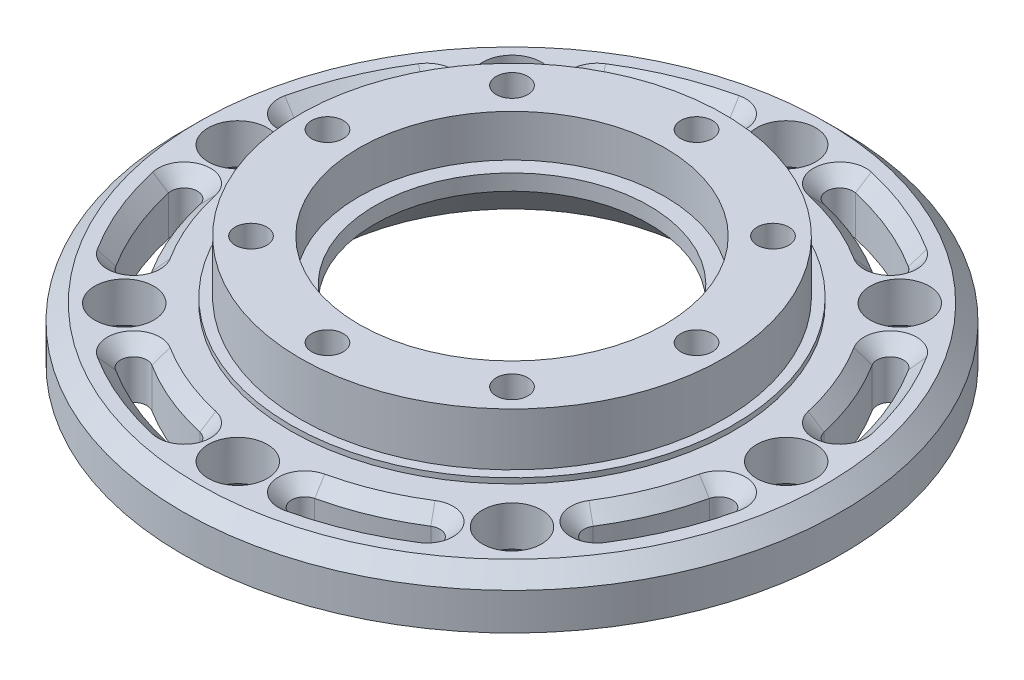
from build123d import *

# Parameters (mm, degrees)
SKETCH1_R            = 62.5
SKETCH1_R_2          = 5.5
SKETCH1_R_3          = 41.5
BOSS_EXTRUDE1_DEPTH  = 10
SKETCH2_R            = 41.5
SKETCH2_R_2          = 3.5
SKETCH2_R_3          = 30
BOSS_EXTRUDE2_DEPTH  = 10
BOSS_EXTRUDE3_START  = -20
SKETCH3_R            = 3.5
BOSS_EXTRUDE3_DEPTH  = 10
SKETCH4_R            = 41.5
SKETCH4_R_2          = 40
CUT_EXTRUDE1_DEPTH   = 10
CHAMFER1_SIZE        = 3
CUT_EXTRUDE4_DEPTH   = 13
BOSS_EXTRUDE4_START  = 1
SKETCH10_R           = 42
SKETCH10_R_2         = 40
BOSS_EXTRUDE4_DEPTH  = 1
BOSS_EXTRUDE9_DEPTH  = 10
CHAMFER7_SIZE        = 2.5
SKETCH18_R           = 3.5
BOSS_EXTRUDE10_DEPTH = 10
SKETCH19_R           = 3
CUT_EXTRUDE7_DEPTH   = 5
CUT_EXTRUDE8_DEPTH   = 15
CHAMFER9_SIZE        = 2.5
SKETCH21_R           = 5.6
CUT_EXTRUDE9_DEPTH   = 15
BOSS_EXTRUDE11_START = -20
SKETCH22_R           = 30
SKETCH22_R_2         = 26
BOSS_EXTRUDE11_DEPTH = 15
SKETCH23_R           = 30
SKETCH23_R_2         = 29
BOSS_EXTRUDE12_DEPTH = 5
CHAMFER10_SIZE       = 10
CUT_EXTRUDE10_START  = -2
SKETCH24_R           = 29
SKETCH24_R_2         = 26
CUT_EXTRUDE10_DEPTH  = 2
BOSS_EXTRUDE13_START = 1
SKETCH25_R           = 40
SKETCH25_R_2         = 29
SKETCH25_R_3         = 3
BOSS_EXTRUDE13_DEPTH = 1
BOSS_EXTRUDE14_START = 10
SKETCH26_R           = 40.15
SKETCH26_R_2         = 40
BOSS_EXTRUDE14_DEPTH = 10


with BuildPart() as part:
    # Sketch1 → Boss-Extrude1 (new body)
    with BuildSketch(Plane(origin=(0, 0, 0), x_dir=(1, 0, 0), z_dir=(0, 1, 0))):
        with Locations(Location((0, 0, 0), (0, 0, 270))):
            Circle(SKETCH1_R)
        with Locations(Location((-52, 0, 0), (0, 0, 270))):
            Circle(SKETCH1_R_2, mode=Mode.SUBTRACT)
        with Locations(Location((-36.769552622, 36.769552622, 0), (0, 0, 270))):
            Circle(SKETCH1_R_2, mode=Mode.SUBTRACT)
        with Locations(Location((0, 52, 0), (0, 0, 270))):
            Circle(SKETCH1_R_2, mode=Mode.SUBTRACT)
        with Locations(Location((36.769552622, 36.769552622, 0), (0, 0, 270))):
            Circle(SKETCH1_R_2, mode=Mode.SUBTRACT)
        with Locations(Location((52, 0, 0), (0, 0, 270))):
            Circle(SKETCH1_R_2, mode=Mode.SUBTRACT)
        with Locations(Location((36.769552622, -36.769552622, 0), (0, 0, 270))):
            Circle(SKETCH1_R_2, mode=Mode.SUBTRACT)
        with Locations(Location((0, -52, 0), (0, 0, 270))):
            Circle(SKETCH1_R_2, mode=Mode.SUBTRACT)
        with Locations(Location((-36.769552622, -36.769552622, 0), (0, 0, 270))):
            Circle(SKETCH1_R_2, mode=Mode.SUBTRACT)
        with Locations(Location((0, 0, 0), (0, 0, 270))):
            Circle(SKETCH1_R_3, mode=Mode.SUBTRACT)
    extrude(amount=BOSS_EXTRUDE1_DEPTH)

    # Sketch2 → Boss-Extrude2 (add, symmetric)
    with BuildSketch(Plane(origin=(0, 10, 0), x_dir=(1, 0, 0), z_dir=(0, 1, 0))):
        with Locations(Location((0, 0, 0), (0, 0, 270))):
            Circle(SKETCH2_R)
        with Locations(Location((0, -35, 0), (0, 0, 270))):
            Circle(SKETCH2_R_2, mode=Mode.SUBTRACT)
        with Locations(Location((-24.748737342, -24.748737342, 0), (0, 0, 270))):
            Circle(SKETCH2_R_2, mode=Mode.SUBTRACT)
        with Locations(Location((24.748737342, -24.748737342, 0), (0, 0, 270))):
            Circle(SKETCH2_R_2, mode=Mode.SUBTRACT)
        with Locations(Location((35, 0, 0), (0, 0, 270))):
            Circle(SKETCH2_R_2, mode=Mode.SUBTRACT)
        with BuildLine():
            ThreePointArc((-38.5, 0), (-35, 3.5), (-31.5, 0))
            ThreePointArc((-31.5, 0), (-35, -3.5), (-38.5, 0))
        make_face(mode=Mode.SUBTRACT)
        with Locations(Location((-24.748737342, 24.748737342, 0), (0, 0, 270))):
            Circle(SKETCH2_R_2, mode=Mode.SUBTRACT)
        with Locations(Location((0, 0, 0), (0, 0, 270))):
            Circle(SKETCH2_R_3, mode=Mode.SUBTRACT)
        with Locations(Location((24.748737342, 24.748737342, 0), (0, 0, 270))):
            Circle(SKETCH2_R_2, mode=Mode.SUBTRACT)
        with Locations(Location((0, 35, 0), (0, 0, 270))):
            Circle(SKETCH2_R_2, mode=Mode.SUBTRACT)
    extrude(amount=BOSS_EXTRUDE2_DEPTH, both=True)

    # Sketch3 → Boss-Extrude3 (add)
    with BuildSketch(Plane(origin=(0, 20, 0), x_dir=(1, 0, 0), z_dir=(0, 1, 0)).offset(BOSS_EXTRUDE3_START)):
        with Locations(Location((-35, 0, 0), (0, 0, 270))):
            Circle(SKETCH3_R)
        with Locations(Location((-24.748737342, 24.748737342, 0), (0, 0, 270))):
            Circle(SKETCH3_R)
        with Locations(Location((0, 35, 0), (0, 0, 270))):
            Circle(SKETCH3_R)
        with Locations(Location((24.748737342, 24.748737342, 0), (0, 0, 270))):
            Circle(SKETCH3_R)
        with Locations(Location((35, 0, 0), (0, 0, 270))):
            Circle(SKETCH3_R)
        with Locations(Location((24.748737342, -24.748737342, 0), (0, 0, 270))):
            Circle(SKETCH3_R)
        with Locations(Location((0, -35, 0), (0, 0, 270))):
            Circle(SKETCH3_R)
        with Locations(Location((-24.748737342, -24.748737342, 0), (0, 0, 270))):
            Circle(SKETCH3_R)
    extrude(amount=BOSS_EXTRUDE3_DEPTH)

    # Sketch4 → Cut-Extrude1 (cut)
    with BuildSketch(Plane(origin=(0, 20, 0), x_dir=(1, 0, 0), z_dir=(0, 1, 0))):
        Circle(SKETCH4_R)
        with Locations(Location((0, 0, 0), (0, 0, 270))):
            Circle(SKETCH4_R_2, mode=Mode.SUBTRACT)
    extrude(amount=-CUT_EXTRUDE1_DEPTH, mode=Mode.SUBTRACT)

    # Chamfer1
    chamfer1_edges = [part.edges().sort_by_distance(p)[0] for p in [
        (0, 10, -62.5),
    ]]
    chamfer(chamfer1_edges, length=CHAMFER1_SIZE)

    # Sketch9 → Cut-Extrude4 (cut)
    with BuildSketch(Plane(origin=(0, 10, 0), x_dir=(1, 0, 0), z_dir=(0, 1, 0))):
        with BuildLine():
            ThreePointArc((-45.31509387, 30.2785777), (-50.351434522, 20.856247064), (-53.452797782, 10.63242255))
            ThreePointArc((-53.452797782, 10.63242255), (-51.488560386, 7.692733544), (-48.54887138, 9.65697094))
            ThreePointArc((-48.54887138, 9.65697094), (-45.732036859, 18.942829902), (-41.157745809, 27.500726534))
            ThreePointArc((-41.157745809, 27.500726534), (-41.847494257, 30.968326148), (-45.31509387, 30.2785777))
        make_face()
        with BuildLine():
            ThreePointArc((-10.63242255, 53.452797782), (-20.856247064, 50.351434522), (-30.2785777, 45.31509387))
            ThreePointArc((-30.2785777, 45.31509387), (-30.968326148, 41.847494257), (-27.500726534, 41.157745809))
            ThreePointArc((-27.500726534, 41.157745809), (-18.942829902, 45.732036859), (-9.65697094, 48.54887138))
            ThreePointArc((-9.65697094, 48.54887138), (-7.692733544, 51.488560386), (-10.63242255, 53.452797782))
        make_face()
        with BuildLine():
            ThreePointArc((30.2785777, 45.31509387), (20.856247064, 50.351434522), (10.63242255, 53.452797782))
            ThreePointArc((10.63242255, 53.452797782), (7.692733544, 51.488560386), (9.65697094, 48.54887138))
            ThreePointArc((9.65697094, 48.54887138), (18.942829902, 45.732036859), (27.500726534, 41.157745809))
            ThreePointArc((27.500726534, 41.157745809), (30.968326148, 41.847494257), (30.2785777, 45.31509387))
        make_face()
        with BuildLine():
            ThreePointArc((53.452797782, 10.63242255), (50.351434522, 20.856247064), (45.31509387, 30.2785777))
            ThreePointArc((45.31509387, 30.2785777), (41.847494257, 30.968326148), (41.157745809, 27.500726534))
            ThreePointArc((41.157745809, 27.500726534), (45.732036859, 18.942829902), (48.54887138, 9.65697094))
            ThreePointArc((48.54887138, 9.65697094), (51.488560386, 7.692733544), (53.452797782, 10.63242255))
        make_face()
        with BuildLine():
            ThreePointArc((45.31509387, -30.2785777), (50.351434522, -20.856247064), (53.452797782, -10.63242255))
            ThreePointArc((53.452797782, -10.63242255), (51.488560386, -7.692733544), (48.54887138, -9.65697094))
            ThreePointArc((48.54887138, -9.65697094), (45.732036859, -18.942829902), (41.157745809, -27.500726534))
            ThreePointArc((41.157745809, -27.500726534), (41.847494257, -30.968326148), (45.31509387, -30.2785777))
        make_face()
        with BuildLine():
            ThreePointArc((10.63242255, -53.452797782), (20.856247064, -50.351434522), (30.2785777, -45.31509387))
            ThreePointArc((30.2785777, -45.31509387), (30.968326148, -41.847494257), (27.500726534, -41.157745809))
            ThreePointArc((27.500726534, -41.157745809), (18.942829902, -45.732036859), (9.65697094, -48.54887138))
            ThreePointArc((9.65697094, -48.54887138), (7.692733544, -51.488560386), (10.63242255, -53.452797782))
        make_face()
        with BuildLine():
            ThreePointArc((-30.2785777, -45.31509387), (-20.856247064, -50.351434522), (-10.63242255, -53.452797782))
            ThreePointArc((-10.63242255, -53.452797782), (-7.692733544, -51.488560386), (-9.65697094, -48.54887138))
            ThreePointArc((-9.65697094, -48.54887138), (-18.942829902, -45.732036859), (-27.500726534, -41.157745809))
            ThreePointArc((-27.500726534, -41.157745809), (-30.968326148, -41.847494257), (-30.2785777, -45.31509387))
        make_face()
        with BuildLine():
            ThreePointArc((-53.452797782, -10.63242255), (-50.351434522, -20.856247064), (-45.31509387, -30.2785777))
            ThreePointArc((-45.31509387, -30.2785777), (-41.847494257, -30.968326148), (-41.157745809, -27.500726534))
            ThreePointArc((-41.157745809, -27.500726534), (-45.732036859, -18.942829902), (-48.54887138, -9.65697094))
            ThreePointArc((-48.54887138, -9.65697094), (-51.488560386, -7.692733544), (-53.452797782, -10.63242255))
        make_face()
    extrude(amount=-CUT_EXTRUDE4_DEPTH, mode=Mode.SUBTRACT)

    # Sketch10 → Boss-Extrude4 (add)
    with BuildSketch(Plane(origin=(0, 10, 0), x_dir=(1, 0, 0), z_dir=(0, 1, 0)).offset(BOSS_EXTRUDE4_START)):
        with Locations(Location((0, 0, 0), (0, 0, 270))):
            Circle(SKETCH10_R)
        with Locations(Location((0, 0, 0), (0, 0, 270))):
            Circle(SKETCH10_R_2, mode=Mode.SUBTRACT)
    extrude(amount=-BOSS_EXTRUDE4_DEPTH)

    # Sketch17 → Boss-Extrude9 (add)
    with BuildSketch(Plane(origin=(0, 10, 0), x_dir=(1, 0, 0), z_dir=(0, 1, 0))):
        with BuildLine():
            ThreePointArc((-45.31509387, 30.2785777), (-50.351434522, 20.856247064), (-53.452797782, 10.63242255))
            ThreePointArc((-53.452797782, 10.63242255), (-51.488560386, 7.692733544), (-48.54887138, 9.65697094))
            ThreePointArc((-48.54887138, 9.65697094), (-45.732036859, 18.942829902), (-41.157745809, 27.500726534))
            ThreePointArc((-41.157745809, 27.500726534), (-41.847494257, 30.968326148), (-45.31509387, 30.2785777))
        make_face()
        with BuildLine():
            ThreePointArc((-10.63242255, 53.452797782), (-20.856247064, 50.351434522), (-30.2785777, 45.31509387))
            ThreePointArc((-30.2785777, 45.31509387), (-30.968326148, 41.847494257), (-27.500726534, 41.157745809))
            ThreePointArc((-27.500726534, 41.157745809), (-18.942829902, 45.732036859), (-9.65697094, 48.54887138))
            ThreePointArc((-9.65697094, 48.54887138), (-7.692733544, 51.488560386), (-10.63242255, 53.452797782))
        make_face()
        with BuildLine():
            ThreePointArc((30.2785777, 45.31509387), (20.856247064, 50.351434522), (10.63242255, 53.452797782))
            ThreePointArc((10.63242255, 53.452797782), (7.692733544, 51.488560386), (9.65697094, 48.54887138))
            ThreePointArc((9.65697094, 48.54887138), (18.942829902, 45.732036859), (27.500726534, 41.157745809))
            ThreePointArc((27.500726534, 41.157745809), (30.968326148, 41.847494257), (30.2785777, 45.31509387))
        make_face()
        with BuildLine():
            ThreePointArc((53.452797782, 10.63242255), (50.351434522, 20.856247064), (45.31509387, 30.2785777))
            ThreePointArc((45.31509387, 30.2785777), (41.847494257, 30.968326148), (41.157745809, 27.500726534))
            ThreePointArc((41.157745809, 27.500726534), (45.732036859, 18.942829902), (48.54887138, 9.65697094))
            ThreePointArc((48.54887138, 9.65697094), (51.488560386, 7.692733544), (53.452797782, 10.63242255))
        make_face()
        with BuildLine():
            ThreePointArc((45.31509387, -30.2785777), (50.351434522, -20.856247064), (53.452797782, -10.63242255))
            ThreePointArc((53.452797782, -10.63242255), (51.488560386, -7.692733544), (48.54887138, -9.65697094))
            ThreePointArc((48.54887138, -9.65697094), (45.732036859, -18.942829902), (41.157745809, -27.500726534))
            ThreePointArc((41.157745809, -27.500726534), (41.847494257, -30.968326148), (45.31509387, -30.2785777))
        make_face()
        with BuildLine():
            ThreePointArc((10.63242255, -53.452797782), (20.856247064, -50.351434522), (30.2785777, -45.31509387))
            ThreePointArc((30.2785777, -45.31509387), (30.968326148, -41.847494257), (27.500726534, -41.157745809))
            ThreePointArc((27.500726534, -41.157745809), (18.942829902, -45.732036859), (9.65697094, -48.54887138))
            ThreePointArc((9.65697094, -48.54887138), (7.692733544, -51.488560386), (10.63242255, -53.452797782))
        make_face()
        with BuildLine():
            ThreePointArc((-30.2785777, -45.31509387), (-20.856247064, -50.351434522), (-10.63242255, -53.452797782))
            ThreePointArc((-10.63242255, -53.452797782), (-7.692733544, -51.488560386), (-9.65697094, -48.54887138))
            ThreePointArc((-9.65697094, -48.54887138), (-18.942829902, -45.732036859), (-27.500726534, -41.157745809))
            ThreePointArc((-27.500726534, -41.157745809), (-30.968326148, -41.847494257), (-30.2785777, -45.31509387))
        make_face()
        with BuildLine():
            ThreePointArc((-53.452797782, -10.63242255), (-50.351434522, -20.856247064), (-45.31509387, -30.2785777))
            ThreePointArc((-45.31509387, -30.2785777), (-41.847494257, -30.968326148), (-41.157745809, -27.500726534))
            ThreePointArc((-41.157745809, -27.500726534), (-45.732036859, -18.942829902), (-48.54887138, -9.65697094))
            ThreePointArc((-48.54887138, -9.65697094), (-51.488560386, -7.692733544), (-53.452797782, -10.63242255))
        make_face()
    extrude(amount=-BOSS_EXTRUDE9_DEPTH)

    # Chamfer7
    chamfer7_edges = [part.edges().sort_by_distance(p)[0] for p in [
        (-36.769552622, 0, 31.269552622),
        (-52, 0, -5.5),
        (-36.769552622, 0, -42.269552622),
        (0, 0, -57.5),
        (36.769552622, 0, -42.269552622),
        (52, 0, -5.5),
        (36.769552622, 0, 31.269552622),
        (0, 0, 46.5),
    ]]
    chamfer(chamfer7_edges, length=CHAMFER7_SIZE)

    # Sketch18 → Boss-Extrude10 (add)
    with BuildSketch(Plane(origin=(0, 10, 0), x_dir=(1, 0, 0), z_dir=(0, 1, 0))):
        with Locations((0, 35)):
            Circle(SKETCH18_R)
        with Locations((24.748737342, 24.748737342)):
            Circle(SKETCH18_R)
        with Locations((35, 0)):
            Circle(SKETCH18_R)
        with Locations((24.748737342, -24.748737342)):
            Circle(SKETCH18_R)
        with Locations((0, -35)):
            Circle(SKETCH18_R)
        with Locations((-24.748737342, -24.748737342)):
            Circle(SKETCH18_R)
        with Locations((-35, 0)):
            Circle(SKETCH18_R)
        with Locations((-24.748737342, 24.748737342)):
            Circle(SKETCH18_R)
    extrude(amount=BOSS_EXTRUDE10_DEPTH)

    # Sketch19 → Cut-Extrude7 (cut)
    with BuildSketch(Plane(origin=(0, 20, 0), x_dir=(1, 0, 0), z_dir=(0, 1, 0))):
        with Locations(Location((-24.748737342, 24.748737342, 0), (0, 0, 270))):
            Circle(SKETCH19_R)
        with Locations(Location((0, 35, 0), (0, 0, 270))):
            Circle(SKETCH19_R)
        with Locations(Location((35, 0, 0), (0, 0, 270))):
            Circle(SKETCH19_R)
        with Locations(Location((24.748737342, -24.748737342, 0), (0, 0, 270))):
            Circle(SKETCH19_R)
        with Locations(Location((0, -35, 0), (0, 0, 270))):
            Circle(SKETCH19_R)
        with Locations(Location((-24.748737342, -24.748737342, 0), (0, 0, 270))):
            Circle(SKETCH19_R)
        with BuildLine():
            ThreePointArc((-38, 0), (-35, -3), (-32, 0))
            Line((-32, 0), (-38, 0))
        make_face()
        with BuildLine():
            Line((-38, 0), (-32, 0))
            ThreePointArc((-32, 0), (-35, 3), (-38, 0))
        make_face()
        with Locations(Location((24.748737342, 24.748737342, 0), (0, 0, 270))):
            Circle(SKETCH19_R)
    extrude(amount=-CUT_EXTRUDE7_DEPTH, mode=Mode.SUBTRACT)

    # Sketch20 → Cut-Extrude8 (cut)
    with BuildSketch(Plane(origin=(0, 10, 0), x_dir=(1, 0, 0), z_dir=(0, 1, 0))):
        with BuildLine():
            ThreePointArc((-46.065319954, 29.124496521), (-50.351434522, 20.856247064), (-53.167229105, 11.978971128))
            ThreePointArc((-53.167229105, 11.978971128), (-51.277859473, 8.990613319), (-48.289501664, 10.879982951))
            ThreePointArc((-48.289501664, 10.879982951), (-45.732036859, 18.942829902), (-41.839143811, 26.452524363))
            ThreePointArc((-41.839143811, 26.452524363), (-42.616245803, 29.901598513), (-46.065319954, 29.124496521))
        make_face()
        with BuildLine():
            ThreePointArc((-11.978971128, 53.167229105), (-20.856247064, 50.351434522), (-29.124496521, 46.065319954))
            ThreePointArc((-29.124496521, 46.065319954), (-29.901598513, 42.616245803), (-26.452524363, 41.839143811))
            ThreePointArc((-26.452524363, 41.839143811), (-18.942829902, 45.732036859), (-10.879982951, 48.289501664))
            ThreePointArc((-10.879982951, 48.289501664), (-8.990613319, 51.277859473), (-11.978971128, 53.167229105))
        make_face()
        with BuildLine():
            ThreePointArc((29.124496521, 46.065319954), (20.856247064, 50.351434522), (11.978971128, 53.167229105))
            ThreePointArc((11.978971128, 53.167229105), (8.990613319, 51.277859473), (10.879982951, 48.289501664))
            ThreePointArc((10.879982951, 48.289501664), (18.942829902, 45.732036859), (26.452524363, 41.839143811))
            ThreePointArc((26.452524363, 41.839143811), (29.901598513, 42.616245803), (29.124496521, 46.065319954))
        make_face()
        with BuildLine():
            ThreePointArc((53.167229105, 11.978971128), (50.351434522, 20.856247064), (46.065319954, 29.124496521))
            ThreePointArc((46.065319954, 29.124496521), (42.616245803, 29.901598513), (41.839143811, 26.452524363))
            ThreePointArc((41.839143811, 26.452524363), (45.732036859, 18.942829902), (48.289501664, 10.879982951))
            ThreePointArc((48.289501664, 10.879982951), (51.277859473, 8.990613319), (53.167229105, 11.978971128))
        make_face()
        with BuildLine():
            ThreePointArc((46.065319954, -29.124496521), (50.351434522, -20.856247064), (53.167229105, -11.978971128))
            ThreePointArc((53.167229105, -11.978971128), (51.277859473, -8.990613319), (48.289501664, -10.879982951))
            ThreePointArc((48.289501664, -10.879982951), (45.732036859, -18.942829902), (41.839143811, -26.452524363))
            ThreePointArc((41.839143811, -26.452524363), (42.616245803, -29.901598513), (46.065319954, -29.124496521))
        make_face()
        with BuildLine():
            ThreePointArc((11.978971128, -53.167229105), (20.856247064, -50.351434522), (29.124496521, -46.065319954))
            ThreePointArc((29.124496521, -46.065319954), (29.901598513, -42.616245803), (26.452524363, -41.839143811))
            ThreePointArc((26.452524363, -41.839143811), (18.942829902, -45.732036859), (10.879982951, -48.289501664))
            ThreePointArc((10.879982951, -48.289501664), (8.990613319, -51.277859473), (11.978971128, -53.167229105))
        make_face()
        with BuildLine():
            ThreePointArc((-29.124496521, -46.065319954), (-20.856247064, -50.351434522), (-11.978971128, -53.167229105))
            ThreePointArc((-11.978971128, -53.167229105), (-8.990613319, -51.277859473), (-10.879982951, -48.289501664))
            ThreePointArc((-10.879982951, -48.289501664), (-18.942829902, -45.732036859), (-26.452524363, -41.839143811))
            ThreePointArc((-26.452524363, -41.839143811), (-29.901598513, -42.616245803), (-29.124496521, -46.065319954))
        make_face()
        with BuildLine():
            ThreePointArc((-53.167229105, -11.978971128), (-50.351434522, -20.856247064), (-46.065319954, -29.124496521))
            ThreePointArc((-46.065319954, -29.124496521), (-42.616245803, -29.901598513), (-41.839143811, -26.452524363))
            ThreePointArc((-41.839143811, -26.452524363), (-45.732036859, -18.942829902), (-48.289501664, -10.879982951))
            ThreePointArc((-48.289501664, -10.879982951), (-51.277859473, -8.990613319), (-53.167229105, -11.978971128))
        make_face()
    extrude(amount=-CUT_EXTRUDE8_DEPTH, mode=Mode.SUBTRACT)

    # Chamfer9
    chamfer9_edges = [part.edges().sort_by_distance(p)[0] for p in [
        (-8.990613319, 10, -51.277859473),
        (-20.856247064, 10, -50.351434522),
        (-29.901598513, 10, -42.616245803),
        (-18.942829902, 10, -45.732036859),
        (29.901598513, 10, -42.616245803),
        (20.856247064, 10, -50.351434522),
        (8.990613319, 10, -51.277859473),
        (18.942829902, 10, -45.732036859),
        (51.277859473, 10, -8.990613319),
        (50.351434522, 10, -20.856247064),
        (42.616245803, 10, -29.901598513),
        (45.732036859, 10, -18.942829902),
        (42.616245803, 10, 29.901598513),
        (50.351434522, 10, 20.856247064),
        (51.277859473, 10, 8.990613319),
        (45.732036859, 10, 18.942829902),
        (8.990613319, 10, 51.277859473),
        (20.856247064, 10, 50.351434522),
        (29.901598513, 10, 42.616245803),
        (18.942829902, 10, 45.732036859),
        (-29.901598513, 10, 42.616245803),
        (-20.856247064, 10, 50.351434522),
        (-8.990613319, 10, 51.277859473),
        (-18.942829902, 10, 45.732036859),
        (-51.277859473, 10, 8.990613319),
        (-50.351434522, 10, 20.856247064),
        (-42.616245803, 10, 29.901598513),
        (-45.732036859, 10, 18.942829902),
        (-42.616245803, 10, -29.901598513),
        (-50.351434522, 10, -20.856247064),
        (-51.277859473, 10, -8.990613319),
        (-45.732036859, 10, -18.942829902),
    ]]
    chamfer(chamfer9_edges, length=CHAMFER9_SIZE)

    # Sketch21 → Cut-Extrude9 (cut)
    with BuildSketch(Plane(origin=(0, 10, 0), x_dir=(1, 0, 0), z_dir=(0, 1, 0))):
        with Locations(Location((-52, 0, 0), (0, 0, 270))):
            Circle(SKETCH21_R)
        with Locations(Location((-36.769552622, 36.769552622, 0), (0, 0, 270))):
            Circle(SKETCH21_R)
        with Locations(Location((0, 52, 0), (0, 0, 270))):
            Circle(SKETCH21_R)
        with Locations(Location((36.769552622, 36.769552622, 0), (0, 0, 270))):
            Circle(SKETCH21_R)
        with Locations(Location((52, 0, 0), (0, 0, 270))):
            Circle(SKETCH21_R)
        with Locations(Location((36.769552622, -36.769552622, 0), (0, 0, 270))):
            Circle(SKETCH21_R)
        with Locations(Location((0, -52, 0), (0, 0, 270))):
            Circle(SKETCH21_R)
        with Locations(Location((-36.769552622, -36.769552622, 0), (0, 0, 270))):
            Circle(SKETCH21_R)
    extrude(amount=-CUT_EXTRUDE9_DEPTH, mode=Mode.SUBTRACT)

    # Sketch22 → Boss-Extrude11 (add)
    with BuildSketch(Plane(origin=(0, 20, 0), x_dir=(1, 0, 0), z_dir=(0, 1, 0)).offset(BOSS_EXTRUDE11_START)):
        with Locations(Location((0, 0, 0), (0, 0, 270))):
            Circle(SKETCH22_R)
        with Locations(Location((0, 0, 0), (0, 0, 270))):
            Circle(SKETCH22_R_2, mode=Mode.SUBTRACT)
    extrude(amount=BOSS_EXTRUDE11_DEPTH)

    # Sketch23 → Boss-Extrude12 (add)
    with BuildSketch(Plane(origin=(0, 15, 0), x_dir=(1, 0, 0), z_dir=(0, 1, 0))):
        Circle(SKETCH23_R)
        with Locations(Location((0, 0, 0), (0, 0, 270))):
            Circle(SKETCH23_R_2, mode=Mode.SUBTRACT)
    extrude(amount=BOSS_EXTRUDE12_DEPTH)

    # Chamfer10
    chamfer10_edges = [part.edges().sort_by_distance(p)[0] for p in [
        (0, 0, -26),
    ]]
    chamfer(chamfer10_edges, length=CHAMFER10_SIZE)

    # Sketch24 → Cut-Extrude10 (cut)
    with BuildSketch(Plane(origin=(0, 15, 0), x_dir=(1, 0, 0), z_dir=(0, 1, 0)).offset(CUT_EXTRUDE10_START)):
        with Locations(Location((0, 0, 0), (0, 0, 270))):
            Circle(SKETCH24_R)
        with Locations(Location((0, 0, 0), (0, 0, 270))):
            Circle(SKETCH24_R_2, mode=Mode.SUBTRACT)
    extrude(amount=CUT_EXTRUDE10_DEPTH, mode=Mode.SUBTRACT)

    # Sketch25 → Boss-Extrude13 (add)
    with BuildSketch(Plane(origin=(0, 20, 0), x_dir=(1, 0, 0), z_dir=(0, 1, 0)).offset(BOSS_EXTRUDE13_START)):
        with Locations(Location((0, 0, 0), (0, 0, 270))):
            Circle(SKETCH25_R)
        with Locations(Location((0, 0, 0), (0, 0, 270))):
            Circle(SKETCH25_R_2, mode=Mode.SUBTRACT)
        with Locations(Location((-24.748737342, 24.748737342, 0), (0, 0, 270))):
            Circle(SKETCH25_R_3, mode=Mode.SUBTRACT)
        with Locations(Location((0, 35, 0), (0, 0, 270))):
            Circle(SKETCH25_R_3, mode=Mode.SUBTRACT)
        with Locations(Location((24.748737342, 24.748737342, 0), (0, 0, 270))):
            Circle(SKETCH25_R_3, mode=Mode.SUBTRACT)
        with Locations(Location((35, 0, 0), (0, 0, 270))):
            Circle(SKETCH25_R_3, mode=Mode.SUBTRACT)
        with Locations(Location((24.748737342, -24.748737342, 0), (0, 0, 270))):
            Circle(SKETCH25_R_3, mode=Mode.SUBTRACT)
        with Locations(Location((0, -35, 0), (0, 0, 270))):
            Circle(SKETCH25_R_3, mode=Mode.SUBTRACT)
        with Locations(Location((-24.748737342, -24.748737342, 0), (0, 0, 270))):
            Circle(SKETCH25_R_3, mode=Mode.SUBTRACT)
        with Locations(Location((-35, 0, 0), (0, 0, 270))):
            Circle(SKETCH25_R_3, mode=Mode.SUBTRACT)
    extrude(amount=-BOSS_EXTRUDE13_DEPTH)

    # Sketch26 → Boss-Extrude14 (add)
    with BuildSketch(Plane(origin=(0, 11, 0), x_dir=(1, 0, 0), z_dir=(0, 1, 0)).offset(BOSS_EXTRUDE14_START)):
        with Locations(Location((0, 0, 0), (0, 0, 270))):
            Circle(SKETCH26_R)
        Circle(SKETCH26_R_2, mode=Mode.SUBTRACT)
    extrude(amount=-BOSS_EXTRUDE14_DEPTH)


solid = part.part
